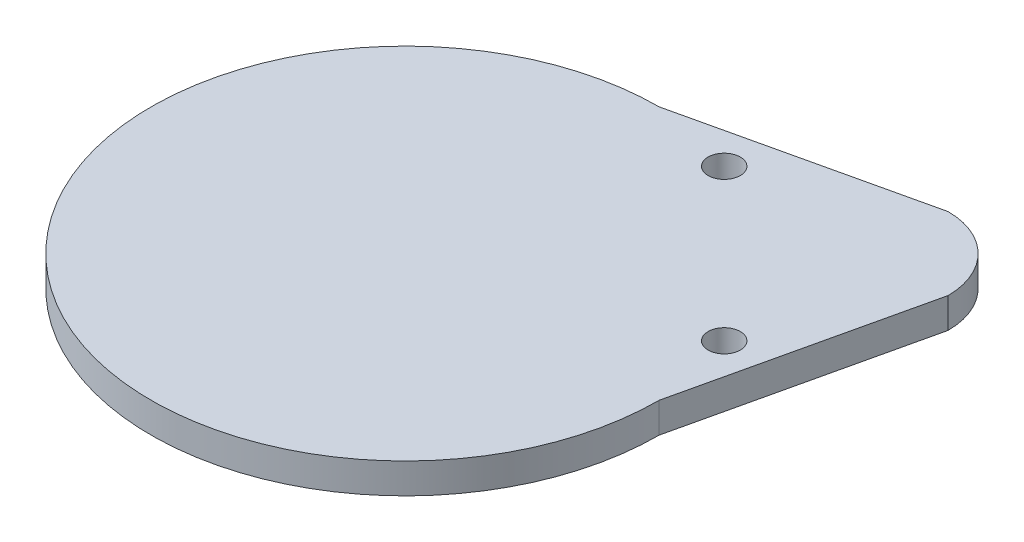
from build123d import *

# Parameters (mm, degrees)
BOSS_EXTRUDE1_DEPTH         = 6.35
SKETCH3_R                   = 44.4881
SKETCH3_R_2                 = 12.7381
CUT_EXTRUDE1_DEPTH          = 7.35
F_1_4_CLEARANCE_HOLE1_D     = 6.7564
F_1_4_CLEARANCE_HOLE1_DEPTH = 25.4
F_1_4_CLEARANCE_HOLE1_TIP   = 2.029827343
SKETCH11_R                  = 44.4881
BOSS_EXTRUDE3_DEPTH         = 3.175
SKETCH12_R                  = 12.7381
BOSS_EXTRUDE4_DEPTH         = 3.175


with BuildPart() as part:
    # Sketch1 → Boss-Extrude1 (new body)
    with BuildSketch(Plane(origin=(0, 0, 0), x_dir=(1, 0, 0), z_dir=(0, 1, 0))):
        with BuildLine():
            Line((0, 53.3781), (49.391408666, 64.669508666))
            ThreePointArc((49.391408666, 64.669508666), (60.19465678, 60.19465678), (64.669508666, 49.391408666))
            Line((64.669508666, 49.391408666), (53.3781, 0))
            ThreePointArc((53.3781, 0), (-37.744016477, -37.744016477), (0, 53.3781))
        make_face()
    extrude(amount=BOSS_EXTRUDE1_DEPTH)

    # Sketch3 → Cut-Extrude1 (cut, through all)
    with BuildSketch(Plane(origin=(0, 6.35, 0), x_dir=(1, 0, 0), z_dir=(0, 1, 0))):
        Circle(SKETCH3_R)
        with Locations((49.391408666, 49.391408666)):
            Circle(SKETCH3_R_2)
    extrude(amount=-CUT_EXTRUDE1_DEPTH, mode=Mode.SUBTRACT)

    # 1/4 Clearance Hole1
    with Locations(Plane.XZ):
        with Locations((49.391408666, -17.641408666), (17.641408666, -49.391408666)):
            Hole(F_1_4_CLEARANCE_HOLE1_D / 2, depth=F_1_4_CLEARANCE_HOLE1_DEPTH)
            with Locations((0, 0, -(F_1_4_CLEARANCE_HOLE1_DEPTH + F_1_4_CLEARANCE_HOLE1_TIP / 2))):  # 118° drill point
                Cone(0, F_1_4_CLEARANCE_HOLE1_D / 2, F_1_4_CLEARANCE_HOLE1_TIP, mode=Mode.SUBTRACT)

    # Sketch11 → Boss-Extrude3 (add)
    with BuildSketch(Plane(origin=(0, 6.35, 0), x_dir=(-1, 0, 0), z_dir=(0, 1, 0))):
        Circle(SKETCH11_R)
    extrude(amount=-BOSS_EXTRUDE3_DEPTH)

    # Sketch12 → Boss-Extrude4 (add)
    with BuildSketch(Plane(origin=(0, 6.35, 0), x_dir=(-1, 0, 0), z_dir=(0, 1, 0))):
        with Locations((-49.391408666, -49.391408666)):
            Circle(SKETCH12_R)
    extrude(amount=-BOSS_EXTRUDE4_DEPTH)


solid = part.part
